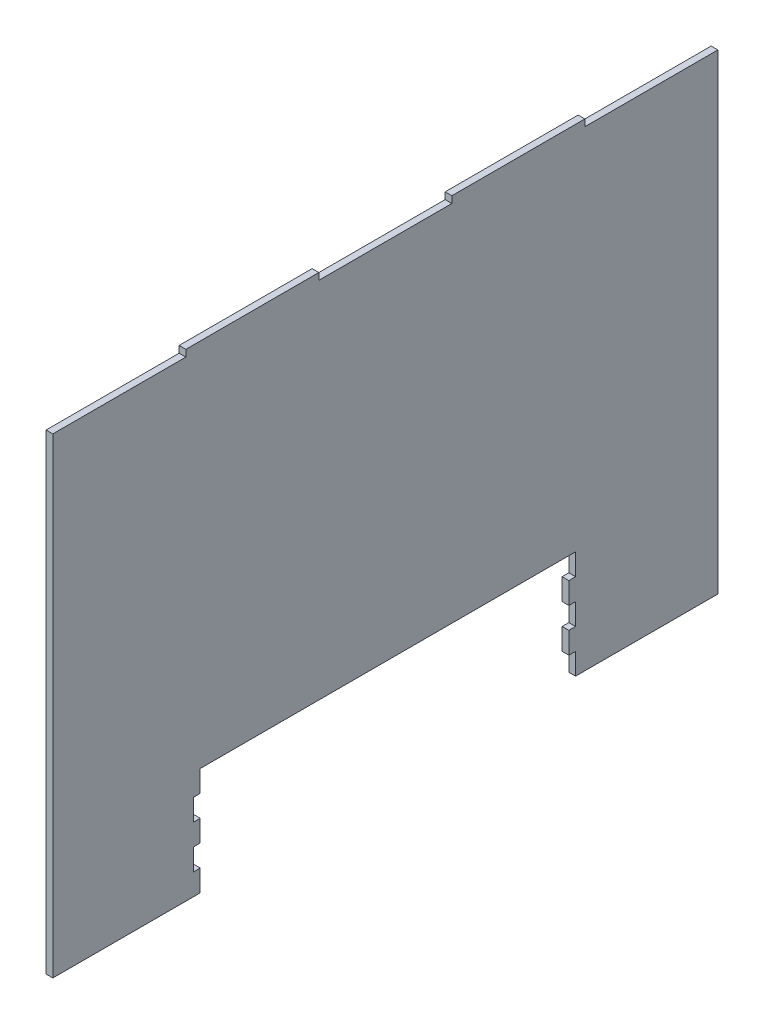
from build123d import *

# Parameters (mm, degrees)
BOSS_EXTRUDE1_DEPTH = 5


with BuildPart() as part:
    # Sketch1 → Boss-Extrude1 (new body)
    with BuildSketch(Plane(origin=(0, 0, 0), x_dir=(0, 0, -1), z_dir=(1, 0, 0))):
        Polygon((-247, 277.5), (-148.2, 277.5), (-148.2, 282.5), (-49.4, 282.5), (-49.4, 277.5), (49.4, 277.5), (49.4, 282.5), (148.2, 282.5), (148.2, 277.5), (247, 277.5), (247, -72.5), (141.262721236, -72.5), (141.262721236, -56.5), (136.262721236, -56.5), (136.262721236, -40.5), (141.262721236, -40.5), (141.262721236, -24.5), (136.262721236, -24.5), (136.262721236, -8.5), (141.262721236, -8.5), (141.262721236, 7.5), (0, 7.5), (-137.5, 7.5), (-137.5, -8.5), (-142.5, -8.5), (-142.5, -24.5), (-137.5, -24.5), (-137.5, -40.359311741), (-142.5, -40.5), (-142.5, -56.5), (-137.5, -56.5), (-137.5, -72.5), (-247, -72.5), align=None)
    extrude(amount=BOSS_EXTRUDE1_DEPTH)


solid = part.part
